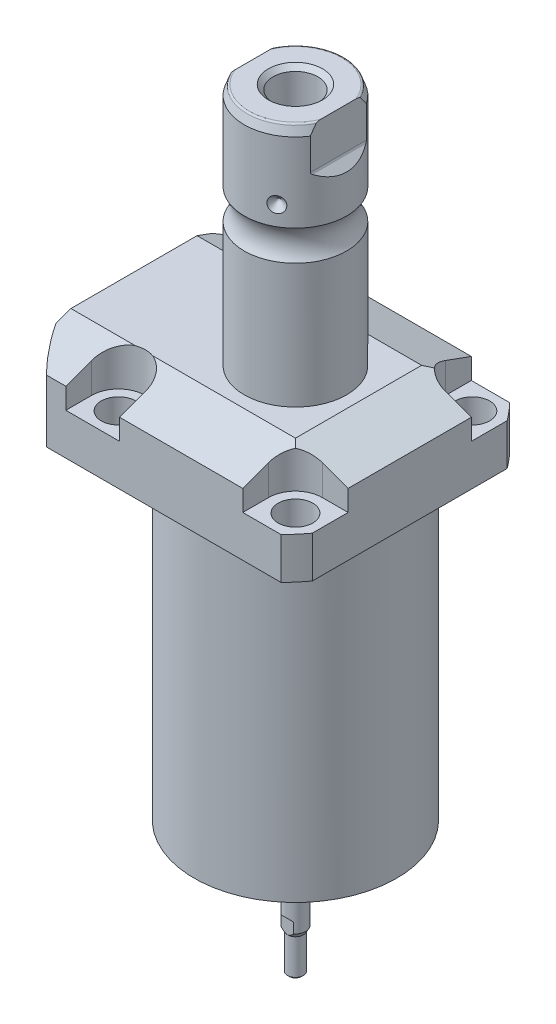
from build123d import *

# Parameters (mm, degrees)
SKETCH1_W                = 70.866
SKETCH1_H                = 85.496
EXTRUDE1_DEPTH           = 122.047
SKETCH2_OUTSIDE_W        = 120.498
SKETCH2_OUTSIDE_H        = 105.868
SKETCH2_OUTSIDE_R        = 50.8
CUT_EXTRUDE1_DEPTH       = 123.047
SKETCH3_W                = 45.1992
SKETCH3_H                = 96.9518
FILLET1_R                = 0.381
CUT_EXTRUDE2_DEPTH       = 12.243
CUT_EXTRUDE9_START       = -51.063
CUT_EXTRUDE9_DEPTH       = 87.496
CUT_EXTRUDE7_DEPTH       = 36.433
CUT_EXTRUDE7_DEPTH_BACK  = 36.433
SKETCH10_R               = 1.1811
SKETCH17_W               = 5.3594
SKETCH17_H               = 12.8522
HOLE1_AT_2_COUNT         = 2
HOLE1_AT_2_PITCH         = 54.864
HOLE1_AT_3_COUNT         = 2
HOLE1_AT_3_PITCH         = 77.589412886
HOLE1_AT_4_COUNT         = 2
HOLE1_AT_4_PITCH         = 54.864
CHAMFER1_SIZE            = 0.635
FILLET2_R                = 0.635
CIRPATTERN1_COUNT        = 3
CUT_EXTRUDE10_DEPTH      = 36.433
CUT_EXTRUDE10_DEPTH_BACK = 36.433
CHAMFER2_SIZE            = 1.4351
SKETCH30_R               = 1.27
CUT_EXTRUDE11_DEPTH      = 7.62
SKETCH31_W               = 2.7051
SKETCH31_H               = 1.3208
CUT_EXTRUDE12_DEPTH      = 3.175


with BuildPart() as part:
    # Sketch1 → Extrude1 (new body)
    with BuildSketch(Plane(origin=(0, 0, 0), x_dir=(0, 0, 1), z_dir=(0, -1, 0))):
        with Locations((0, 7.315)):
            Rectangle(SKETCH1_W, SKETCH1_H)
    extrude(amount=-EXTRUDE1_DEPTH)

    # Sketch2 outside → Cut-Extrude1 (cut, through all)
    with BuildSketch(Plane.XZ):
        with Locations((-7.315, 0)):
            Rectangle(SKETCH2_OUTSIDE_W, SKETCH2_OUTSIDE_H)
        with Locations((-5.4102, 0)):
            Circle(SKETCH2_OUTSIDE_R, mode=Mode.SUBTRACT)
    extrude(amount=-CUT_EXTRUDE1_DEPTH, mode=Mode.SUBTRACT)

    # Sketch3 → Cut-Revolve1 (revolve, cut)
    with BuildSketch(Plane(origin=(0, 0, 0), x_dir=(0, 0, -1), z_dir=(1, 0, 0))):
        with Locations((53.9941, 48.4759)):
            Rectangle(SKETCH3_W, SKETCH3_H)
    revolve(axis=Axis((0, -93.345, 0), (0, 1, 0)), mode=Mode.SUBTRACT)

    # Fillet1
    fillet1_edges = [part.edges().sort_by_distance(p)[0] for p in [
        (0, 96.9518, 31.3945),
    ]]
    fillet(fillet1_edges, radius=FILLET1_R)

    # Sketch4 → Cut-Extrude2 (cut)
    with BuildSketch(Plane(origin=(0, 122.047, 0), x_dir=(-1, 0, 0), z_dir=(0, 1, 0))):
        with BuildLine():
            Line((-19.1008, -35.433), (-19.1008, -27.432))
            ThreePointArc((-19.1008, -27.432), (-21.540951985, -21.540951985), (-27.432, -19.1008))
            Line((-27.432, -19.1008), (-35.433, -19.1008))
            Line((-35.433, -19.1008), (-35.433, -35.433))
            Line((-35.433, -35.433), (-19.1008, -35.433))
        make_face()
        with BuildLine():
            Line((35.7632, -35.433), (19.1008, -35.433))
            Line((19.1008, -35.433), (19.1008, -27.432))
            ThreePointArc((19.1008, -27.432), (27.432, -19.1008), (35.7632, -27.432))
            Line((35.7632, -27.432), (35.7632, -35.433))
        make_face()
        with BuildLine():
            Line((19.1008, 35.433), (19.1008, 27.432))
            ThreePointArc((19.1008, 27.432), (27.432, 19.1008), (35.7632, 27.432))
            Line((35.7632, 27.432), (35.7632, 35.433))
            Line((35.7632, 35.433), (19.1008, 35.433))
        make_face()
        with BuildLine():
            Line((-27.432, 19.1008), (-35.433, 19.1008))
            Line((-35.433, 19.1008), (-35.433, 35.433))
            Line((-35.433, 35.433), (-19.1008, 35.433))
            Line((-19.1008, 35.433), (-19.1008, 27.432))
            ThreePointArc((-19.1008, 27.432), (-21.540951985, 21.540951985), (-27.432, 19.1008))
        make_face()
    extrude(amount=-CUT_EXTRUDE2_DEPTH, mode=Mode.SUBTRACT)

    # Sketch5 → Cut-Extrude9 (cut)
    with BuildSketch(Plane(origin=(0, 0, 0), x_dir=(0, 0, -1), z_dir=(1, 0, 0)).offset(CUT_EXTRUDE9_START)):
        Polygon((-19.558, 122.047), (-35.433, 116.268972531), (-35.433, 122.047), align=None)
    cut_extrude9 = extrude(amount=CUT_EXTRUDE9_DEPTH, mode=Mode.SUBTRACT)

    # Mirror1: Cut-Extrude9 across plane
    add(cut_extrude9.mirror(Plane.XY), mode=Mode.SUBTRACT)

    # Sketch9 → Cut-Extrude7 (cut, two sides)
    with BuildSketch(Plane.XY) as cut_extrude7_sk:
        Polygon((19.558, 122.047), (35.433, 116.268972531), (35.433, 122.047), align=None)
    extrude(amount=CUT_EXTRUDE7_DEPTH, mode=Mode.SUBTRACT)
    extrude(cut_extrude7_sk.sketch, amount=-CUT_EXTRUDE7_DEPTH_BACK, mode=Mode.SUBTRACT)

    # Sketch20 → Cut-Revolve4 (revolve, cut)
    with BuildSketch(Plane(origin=(-35.0774, 88.9, -18.1102), x_dir=(0, 1, 0), z_dir=(1, 0, 0)), mode=Mode.PRIVATE) as cut_revolve4_sk:
        Polygon((8.0518, 38.3413), (9.4996, 38.3413), (9.4996, 35.8902), (10.5156, 35.8902), (10.5156, 33.8836), (21.4884, 33.8836), (21.4884, 32.639), (8.0518, 32.639), align=None)
    cut_revolve4 = revolve(cut_revolve4_sk.sketch.rotate(Axis((-35.0774, 81.620304954, 14.5288), (0, 1, 0)), 180), axis=Axis((-35.0774, 81.620304954, 14.5288), (0, 1, 0)), mode=Mode.SUBTRACT)  # turned: the seam where the file's is

    # Mirror10: Cut-Revolve4 across plane
    add(cut_revolve4.mirror(Plane.XY), mode=Mode.SUBTRACT)

    # Sketch15 → Revolve3 (revolve)
    with BuildSketch(Plane(origin=(0, 0, 0), x_dir=(0, 0, -1), z_dir=(1, 0, 0)), mode=Mode.PRIVATE) as revolve3_sk:
        with BuildLine():
            Line((0, 122.047), (15.875, 122.047))
            Line((15.875, 122.047), (15.875, 160.67190643))
            ThreePointArc((15.875, 160.67190643), (14.3256, 165.379), (15.875, 170.08609357))
            Line((15.875, 170.08609357), (15.875, 194.56399416))
            Line((15.875, 194.56399416), (14.81184082, 197.485))
            Line((14.81184082, 197.485), (0, 197.485))
            Line((0, 197.485), (0, 122.047))
        make_face()
    revolve(revolve3_sk.sketch.rotate(Axis((0, 250.290824608, 0), (0, -1, 0)), 180), axis=Axis((0, 250.290824608, 0), (0, -1, 0)))  # turned: the seam where the file's is

    # Sketch17 → Hole1 (revolve, cut)
    with BuildSketch(Plane(origin=(27.432, 109.804, -27.432), x_dir=(0, 0, 1), z_dir=(1, 0, 0))):
        with Locations((2.6797, 6.4261)):
            Rectangle(SKETCH17_W, SKETCH17_H)
    hole1 = revolve(axis=Axis((27.432, -0.196, -27.432), (0, 1, 0)), mode=Mode.SUBTRACT)

    # Hole1 at 2: Hole1 ×2
    with Locations(*[(0, 0, i * HOLE1_AT_2_PITCH) for i in range(1, HOLE1_AT_2_COUNT)]):
        add(hole1, mode=Mode.SUBTRACT)

    # Hole1 at 3: Hole1 ×2
    with Locations(*[Vector(-0.707106781, 0, 0.707106781) * (i * HOLE1_AT_3_PITCH) for i in range(1, HOLE1_AT_3_COUNT)]):
        add(hole1, mode=Mode.SUBTRACT)

    # Hole1 at 4: Hole1 ×2
    with Locations(*[(-i * HOLE1_AT_4_PITCH, 0, 0) for i in range(1, HOLE1_AT_4_COUNT)]):
        add(hole1, mode=Mode.SUBTRACT)

    # Chamfer1
    chamfer1_edges = [part.edges().sort_by_distance(p)[0] for p in [
        (-35.0774, 99.4156, 15.7734),
        (-35.0774, 99.4156, -15.7734),
    ]]
    chamfer(chamfer1_edges, length=CHAMFER1_SIZE)

    # Sketch21 → Cut-Revolve5 (revolve, cut)
    with BuildSketch(Plane.XZ.offset(-109.4486)):
        Polygon((-50.063, -1.9304), (-49.809, -1.9304), (-49.809, -6.7564), (-47.2563, -7.440393904), (-46.695693904, -8.001), (-30.759, -8.001), (-30.759, -12.9794), (-50.063, -12.9794), align=None)
    cut_revolve5 = revolve(axis=Axis((-57.549532301, 109.4486, -12.9794), (1, 0, 0)), mode=Mode.SUBTRACT)

    # Mirror13: Cut-Revolve5 across plane
    add(cut_revolve5.mirror(Plane.XY), mode=Mode.SUBTRACT)

    # Fillet2
    fillet2_edges = [part.edges().sort_by_distance(p)[0] for p in [
        (0, 197.485, -14.81184082),
    ]]
    fillet(fillet2_edges, radius=FILLET2_R)

    # Sketch26 → Cut-Revolve7 (revolve, cut)
    with BuildSketch(Plane.XY, mode=Mode.PRIVATE) as cut_revolve7_sk:
        Polygon((-15.875, 178.46), (-13.462, 176.047), (-15.875, 176.047), align=None)
    cut_revolve7 = revolve(cut_revolve7_sk.sketch.rotate(Axis((-39.772000707, 176.047, 0), (1, 0, 0)), 90), axis=Axis((-39.772000707, 176.047, 0), (1, 0, 0)), mode=Mode.SUBTRACT)  # turned: the seam where the file's is

    # CirPattern1: Cut-Revolve7 ×3 about axis
    cirpattern1_axis = Axis((0, 250.290824608, 0), (0, 1, 0))
    for i in range(1, CIRPATTERN1_COUNT):
        add(cut_revolve7.rotate(cirpattern1_axis, i * 360 / CIRPATTERN1_COUNT), mode=Mode.SUBTRACT)

    # Sketch27 → Hole2 (revolve, cut)
    with BuildSketch(Plane(origin=(0, 197.485, 0), x_dir=(0, 0, 1), z_dir=(1, 0, 0))):
        Polygon((0, 0), (0, 28.812118634), (6.9469, 24.638), (6.9469, 0), align=None)
    revolve(axis=Axis((0, 201.729199587, 0), (0, -1, 0)), mode=Mode.SUBTRACT)

    # Sketch29 → Cut-Extrude10 (cut, two sides)
    with BuildSketch(Plane.XY) as cut_extrude10_sk:
        with BuildLine():
            Line((13.284, 197.485), (13.284, 184.785))
            ThreePointArc((13.284, 184.785), (13.342003912, 184.493394643), (13.507185078, 184.246183558))
            Line((13.507185078, 184.246183558), (16.332, 181.421368636))
            Line((16.332, 181.421368636), (16.332, 197.485))
            Line((16.332, 197.485), (13.284, 197.485))
        make_face()
        with BuildLine():
            Line((-16.332, 197.485), (-13.284, 197.485))
            Line((-13.284, 197.485), (-13.284, 184.785))
            ThreePointArc((-13.284, 184.785), (-13.342003912, 184.493394643), (-13.507185078, 184.246183558))
            Line((-13.507185078, 184.246183558), (-16.332, 181.421368636))
            Line((-16.332, 181.421368636), (-16.332, 197.485))
        make_face()
    extrude(amount=CUT_EXTRUDE10_DEPTH, mode=Mode.SUBTRACT)
    extrude(cut_extrude10_sk.sketch, amount=-CUT_EXTRUDE10_DEPTH_BACK, mode=Mode.SUBTRACT)

    # Chamfer2
    chamfer2_edges = [part.edges().sort_by_distance(p)[0] for p in [
        (0, 197.485, -6.9469),
    ]]
    chamfer(chamfer2_edges, length=CHAMFER2_SIZE)

    # Sketch30 → Cut-Extrude11 (cut)
    with BuildSketch(Plane.XZ):
        with Locations(Location((19.431, 0, 0), (0, 0, 270))):  # turned: the seam where the file's is
            Circle(SKETCH30_R)
        with Locations(Location((18.768904731, -5.029112865, 0), (0, 0, 270))):  # turned: the seam where the file's is
            Circle(SKETCH30_R)
        with Locations(Location((-9.7155, -16.827739621, 0), (0, 0, 270))):  # turned: the seam where the file's is
            Circle(SKETCH30_R)
        with Locations(Location((-13.739791865, -13.739791865, 0), (0, 0, 270))):  # turned: the seam where the file's is
            Circle(SKETCH30_R)
        with Locations(Location((-9.7155, 16.827739621, 0), (0, 0, 270))):  # turned: the seam where the file's is
            Circle(SKETCH30_R)
        with Locations(Location((-5.029112865, 18.768904731, 0), (0, 0, 270))):  # turned: the seam where the file's is
            Circle(SKETCH30_R)
    extrude(amount=-CUT_EXTRUDE11_DEPTH, mode=Mode.SUBTRACT)

    # Sketch31 → Cut-Revolve8 (revolve, cut)
    with BuildSketch(Plane(origin=(0, 0, 0), x_dir=(0, 0, -1), z_dir=(1, 0, 0)), mode=Mode.PRIVATE) as cut_revolve8_sk:
        with Locations((12.99845, 0.6604)):
            Rectangle(SKETCH31_W, SKETCH31_H)
    revolve(cut_revolve8_sk.sketch.rotate(Axis((0, 61.617584575, 0), (0, -1, 0)), 180), axis=Axis((0, 61.617584575, 0), (0, -1, 0)), mode=Mode.SUBTRACT)  # turned: the seam where the file's is

    # Sketch32 → Revolve5 (revolve)
    with BuildSketch(Plane(origin=(0, 0, 0), x_dir=(0, 0, -1), z_dir=(1, 0, 0)), mode=Mode.PRIVATE) as revolve5_sk:
        Polygon((3.175, 0), (3.175, -28.391371375), (2.4384, -29.6672), (2.4384, -40.5892), (1.9304, -41.0972), (0, -41.0972), (0, 0), align=None)
    revolve(revolve5_sk.sketch.rotate(Axis((0, 46.642918558, 0), (0, -1, 0)), 180), axis=Axis((0, 46.642918558, 0), (0, -1, 0)))  # turned: the seam where the file's is

    # Sketch33 → Cut-Extrude12 (cut, symmetric)
    with BuildSketch(Plane(origin=(0, 0, 0), x_dir=(0, 0, -1), z_dir=(1, 0, 0))):
        Polygon((2.5019, -29.557214774), (2.5019, -25.2222), (3.2639, -24.4602), (3.2639, -29.557214774), align=None)
    cut_extrude12 = extrude(amount=CUT_EXTRUDE12_DEPTH, both=True, mode=Mode.SUBTRACT)

    # Mirror14: Cut-Extrude12 across plane
    add(cut_extrude12.mirror(Plane.XY), mode=Mode.SUBTRACT)


with BuildPart() as body_2:
    # Sketch10 → Revolve4 (revolve)
    with BuildSketch(Plane(origin=(-35.0774, 88.9, -18.1102), x_dir=(0, 1, 0), z_dir=(1, 0, 0))):
        with Locations((8.3185, 8.1026)):
            Circle(SKETCH10_R)
    revolve(axis=Axis((-35.0774, 87.86749, -14.5288), (0, 1, 0)))


with BuildPart() as body_3:
    # Mirror12: mirrored copy
    add(body_2.part.mirror(Plane.XY))


solid = Compound([part.part, body_2.part, body_3.part])
